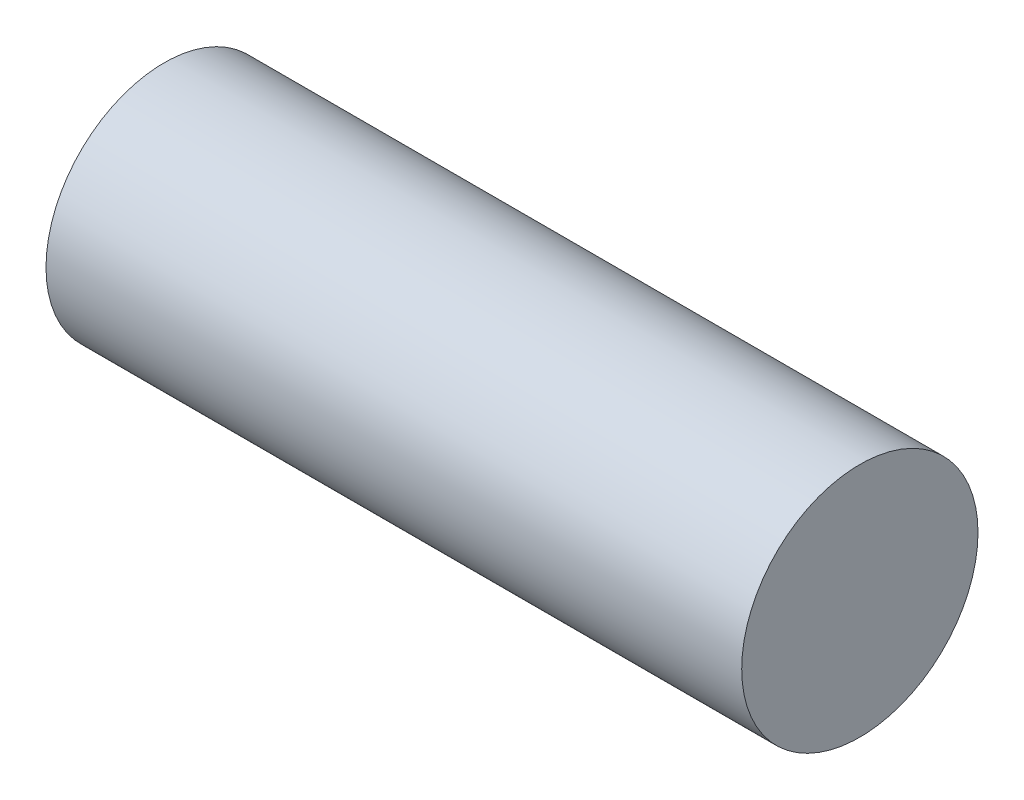
from build123d import *

# Parameters (mm, degrees)
SKETCH_1_R      = 12.567292718
EXTRUDE_1_DEPTH = 74


with BuildPart() as part:
    # 草图1 → 凸台-拉伸1 (new body)
    with BuildSketch(Plane(origin=(277.841332811, 0, 0), x_dir=(0, 0, -1), z_dir=(1, 0, 0))):
        with Locations((-1444.071593016, -596.492156935)):
            Circle(SKETCH_1_R)
    extrude(amount=-EXTRUDE_1_DEPTH)


solid = part.part
